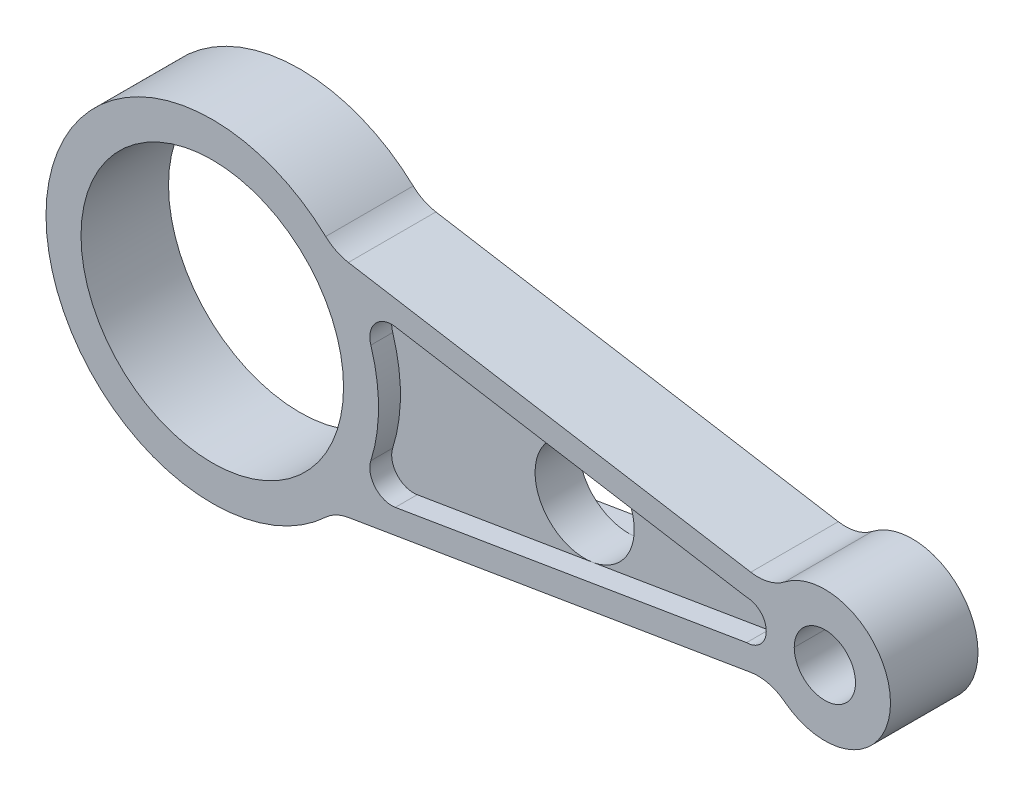
from build123d import *

# Parameters (mm, degrees)
SKETCH1_R           = 30
SKETCH1_R_2         = 7
BOSS_EXTRUDE1_DEPTH = 10
FILLET1_R           = 10
FILLET3_R           = 10
CUT_EXTRUDE1_DEPTH  = 5
CUT_EXTRUDE3_START  = 10
SKETCH12_R          = 11.339564337
CUT_EXTRUDE3_DEPTH  = 21


with BuildPart() as part:
    # Sketch1 → Boss-Extrude1 (new body, symmetric)
    with BuildSketch(Plane.XY):
        with BuildLine():
            Line((128.063755469, 9.084385863), (27.935473676, 25.760615491))
            ThreePointArc((27.935473676, 25.760615491), (-38, 0), (27.935473676, -25.760615491))
            Line((27.935473676, -25.760615491), (128.063755469, -9.084385863))
            ThreePointArc((128.063755469, -9.084385863), (155, 0), (128.063755469, 9.084385863))
        make_face()
        Circle(SKETCH1_R, mode=Mode.SUBTRACT)
        with Locations((140, 0)):
            Circle(SKETCH1_R_2, mode=Mode.SUBTRACT)
    extrude(amount=BOSS_EXTRUDE1_DEPTH, both=True)

    # Fillet1
    fillet1_edges = [part.edges().sort_by_distance(p)[0] for p in [
        (27.935473676, -25.760615491, 0),
        (27.935473676, 25.760615491, 0),
    ]]
    fillet(fillet1_edges, radius=FILLET1_R)

    # Fillet3
    fillet3_edges = [part.edges().sort_by_distance(p)[0] for p in [
        (128.063755469, -9.084385863, 0),
        (128.063755469, 9.084385863, 0),
    ]]
    fillet(fillet3_edges, radius=FILLET3_R)

    # Sketch2 → Cut-Extrude1 (cut)
    with BuildSketch(Plane.XY.offset(10)):
        with BuildLine():
            Line((41.828554558, 17.870982725), (122.111301675, 4.5))
            ThreePointArc((122.111301675, 4.5), (126.611301675, 0), (122.111301675, -4.5))
            Line((122.111301675, -4.5), (41.828554558, -17.870982725))
            ThreePointArc((41.828554558, -17.870982725), (37.231968897, -16.217361812), (36.238855523, -11.43439331))
            ThreePointArc((36.238855523, -11.43439331), (38, 0), (36.238855523, 11.43439331))
            ThreePointArc((36.238855523, 11.43439331), (37.231968897, 16.217361812), (41.828554558, 17.870982725))
        make_face()
    cut_extrude1 = extrude(amount=-CUT_EXTRUDE1_DEPTH, mode=Mode.SUBTRACT)

    # Mirror1: Cut-Extrude1 across plane
    add(cut_extrude1.mirror(Plane.XY), mode=Mode.SUBTRACT)

    # Sketch12 → Cut-Extrude3 (cut, through all)
    with BuildSketch(Plane.XY.offset(CUT_EXTRUDE3_START)):
        with Locations((80.10699969, 0)):
            Circle(SKETCH12_R)
    extrude(amount=-CUT_EXTRUDE3_DEPTH, mode=Mode.SUBTRACT)


solid = part.part
